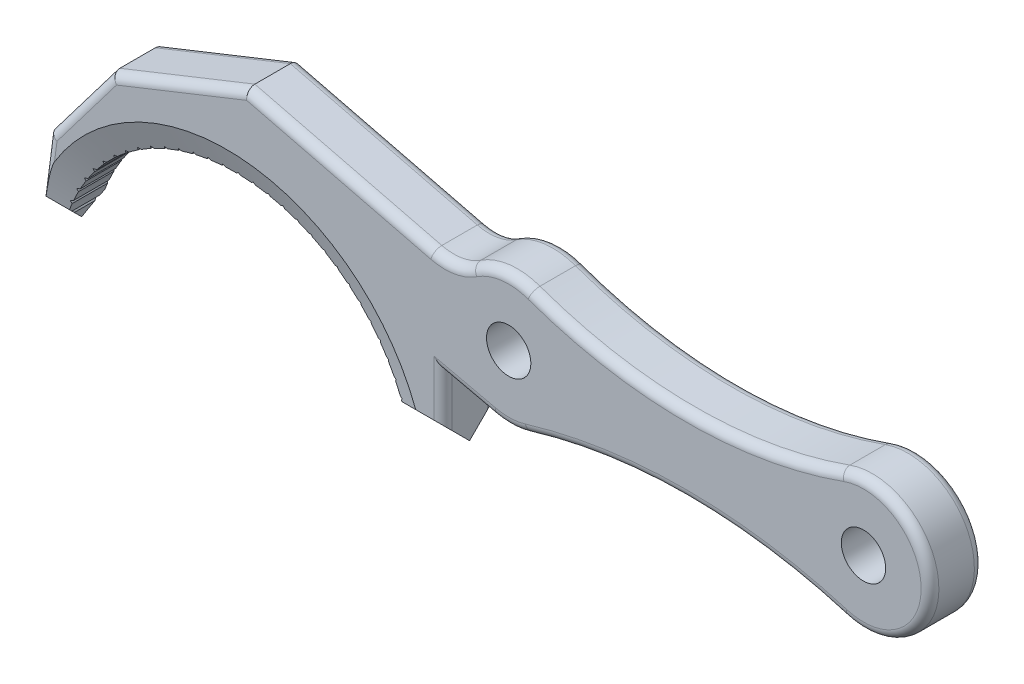
from build123d import *

# Parameters (mm, degrees)
SKETCH1_R           = 3.174999996
BOSS_EXTRUDE1_DEPTH = 3.81
CUT_EXTRUDE1_START  = -28.077464207
CUT_EXTRUDE1_DEPTH  = 129.753997978
CHAMFER1_SIZE       = 1.27
CHAMFER1_SIZE2      = 3.489296323
CUT_EXTRUDE2_DEPTH  = 8.6200001
CIRPATTERN1_COUNT   = 30
CIRPATTERN1_ANGLE   = 140
FILLET1_R           = 1.27


with BuildPart() as part:
    # Sketch1 → Boss-Extrude1 (new body, symmetric)
    with BuildSketch(Plane.XY):
        with BuildLine():
            Line((24.593444248, 0), (30.943444248, 0))
            Line((30.943444248, 0), (30.943444248, 10.16))
            Line((30.943444248, 10.16), (38.22885109, 8.494535917))
            ThreePointArc((38.22885109, 8.494535917), (40.673245311, 8.260434533), (43.096257726, 8.659028812))
            ThreePointArc((43.096257726, 8.659028812), (65.751533771, 11.993930397), (88.406809816, 8.659028812))
            ThreePointArc((88.406809816, 8.659028812), (100.67325401, 18.029937352), (87.932083212, 26.744416495))
            ThreePointArc((87.932083212, 26.744416495), (65.751533771, 22.882251223), (43.570984329, 26.744416495))
            ThreePointArc((43.570984329, 26.744416495), (39.216497636, 27.237130536), (35.102269401, 25.728009095))
            ThreePointArc((35.102269401, 25.728009095), (32.408902751, 24.661086907), (29.513777721, 24.765))
            Line((29.513777721, 24.765), (2.745715563, 31.383672495))
            Line((2.745715563, 31.383672495), (-16.585766286, 23.686929062))
            Line((-16.585766286, 23.686929062), (-25.527743463, 11.903782272))
            Line((-25.527743463, 11.903782272), (-27.077464207, 0))
            Line((-27.077464207, 0), (-24.593444248, 0))
            ThreePointArc((-24.593444248, 0), (0, 19.05), (24.593444248, 0))
        make_face()
        with Locations((40.351533771, 17.78)):
            Circle(SKETCH1_R, mode=Mode.SUBTRACT)
        with Locations((91.151533771, 17.78)):
            Circle(SKETCH1_R, mode=Mode.SUBTRACT)
    extrude(amount=BOSS_EXTRUDE1_DEPTH, both=True)

    # Sketch2 → Cut-Extrude1 (cut)
    with BuildSketch(Plane(origin=(0, 0, 0), x_dir=(0, 0, -1), z_dir=(1, 0, 0)).offset(CUT_EXTRUDE1_START)):
        Polygon((0, 0), (3.81, 3.81), (3.81, 0), align=None)
    cut_extrude1 = extrude(amount=CUT_EXTRUDE1_DEPTH, mode=Mode.SUBTRACT)

    # Mirror1: Cut-Extrude1 across plane
    add(cut_extrude1.mirror(Plane.XY), mode=Mode.SUBTRACT)

    # Chamfer1
    chamfer1_edges = [part.edges().sort_by_distance(p)[0] for p in [
        (0, 19.05, -3.81),
        (0, 19.05, 3.81),
    ]]
    chamfer1_side = [part.faces().sort_by_distance(p)[0] for p in [
        (0, 19.05, 0),
    ]]
    chamfer(chamfer1_edges, length=CHAMFER1_SIZE, length2=CHAMFER1_SIZE2, reference=chamfer1_side[0])

    # Sketch4 → Cut-Extrude2 (cut, through all)
    with BuildSketch(Plane.XY.offset(3.81)):
        Polygon((23.938990025, 3.039538145), (22.084245194, -0.445280344), (20.209632779, 4.334116386), align=None)
    cut_extrude2 = extrude(amount=-CUT_EXTRUDE2_DEPTH, mode=Mode.SUBTRACT)

    # CirPattern1: Cut-Extrude2 ×30 about axis
    cirpattern1_axis = Axis((0, -6.35, 0), (0, 0, 1))
    for i in range(1, CIRPATTERN1_COUNT):
        add(cut_extrude2.rotate(cirpattern1_axis, i * CIRPATTERN1_ANGLE / (CIRPATTERN1_COUNT - 1)), mode=Mode.SUBTRACT)

    # Fillet1
    fillet1_edges = [part.edges().sort_by_distance(p)[0] for p in [
        (34.586147669, 9.327267958, -3.81),
        (40.673245311, 8.260434533, -3.81),
        (65.751533771, 11.993930397, -3.81),
        (100.67325401, 18.029937352, -3.81),
        (16.129746642, 28.074336247, -3.81),
        (32.408902751, 24.661086907, -3.81),
        (39.216497636, 27.237130536, -3.81),
        (34.586147669, 9.327267958, 3.81),
        (40.673245311, 8.260434533, 3.81),
        (65.751533771, 11.993930397, 3.81),
        (100.67325401, 18.029937352, 3.81),
        (16.129746642, 28.074336247, 3.81),
        (32.408902751, 24.661086907, 3.81),
        (39.216497636, 27.237130536, 3.81),
        (30.943444248, 6.985, -3.81),
        (30.943444248, 6.985, 3.81),
        (65.751533771, 22.882251223, -3.81),
        (65.751533771, 22.882251223, 3.81),
        (-25.947520852, 8.679369971, -3.81),
        (-25.947520852, 8.679369971, 3.81),
        (-21.056754875, 17.795355667, 3.81),
        (-21.056754875, 17.795355667, -3.81),
        (-6.920025362, 27.535300778, -3.81),
        (-6.920025362, 27.535300778, 3.81),
    ]]
    fillet(fillet1_edges, radius=FILLET1_R)


solid = part.part
